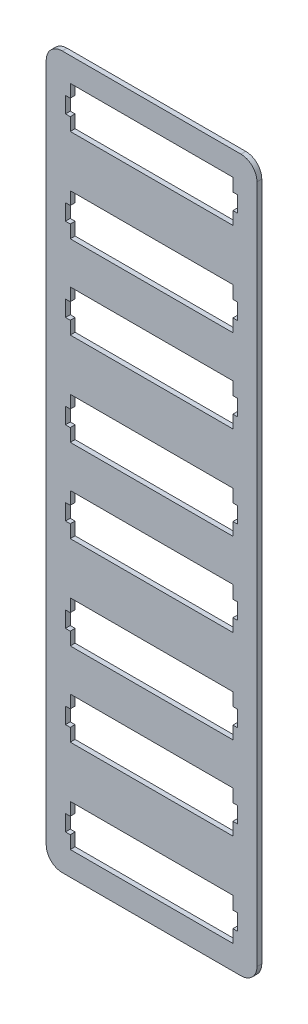
from build123d import *

# Parameters (mm, degrees)
SKIZZE1_W                       = 131.5
SKIZZE1_H                       = 114
SKIZZE1_W_2                     = 101.5
SKIZZE1_H_2                     = 26
AUFSATZ_LINEAR_AUSTRAGEN1_DEPTH = 3
SKIZZE2_W                       = 3
SKIZZE2_H                       = 10
SCHNITT_LINEAR_AUSTRAGEN2_DEPTH = 3
LINEARES_MUSTER2_COUNT          = 4
LINEARES_MUSTER2_PITCH          = 110
VERRUNDUNG1_R                   = 10


with BuildPart() as part:
    # Skizze1 → Aufsatz-Linear austragen1 (new body)
    with BuildSketch(Plane.XY):
        with Locations((65.75, 57)):
            Rectangle(SKIZZE1_W, SKIZZE1_H)
        with Locations((65.75, 28)):
            Rectangle(SKIZZE1_W_2, SKIZZE1_H_2, mode=Mode.SUBTRACT)
        with Locations((65.75, 86)):
            Rectangle(SKIZZE1_W_2, SKIZZE1_H_2, mode=Mode.SUBTRACT)
    aufsatz_linear_austragen1 = extrude(amount=AUFSATZ_LINEAR_AUSTRAGEN1_DEPTH)

    # Skizze2 → Schnitt-Linear austragen2 (cut)
    with BuildSketch(Plane.XY.offset(3)):
        with Locations((13.5, 86)):
            Rectangle(SKIZZE2_W, SKIZZE2_H)
        with Locations((118, 86)):
            Rectangle(SKIZZE2_W, SKIZZE2_H)
        with Locations((13.5, 28)):
            Rectangle(SKIZZE2_W, SKIZZE2_H)
        with Locations((118, 28)):
            Rectangle(SKIZZE2_W, SKIZZE2_H)
    schnitt_linear_austragen2 = extrude(amount=-SCHNITT_LINEAR_AUSTRAGEN2_DEPTH, mode=Mode.SUBTRACT)

    # Lineares Muster2: Aufsatz-Linear austragen1, Schnitt-Linear austragen2 ×4
    with Locations(*[(0, -i * LINEARES_MUSTER2_PITCH, 0) for i in range(1, LINEARES_MUSTER2_COUNT)]):
        add(aufsatz_linear_austragen1)
        add(schnitt_linear_austragen2, mode=Mode.SUBTRACT)

    # Verrundung1
    verrundung1_edges = [part.edges().sort_by_distance(p)[0] for p in [
        (131.5, -330, 1.5),
        (0, -330, 1.5),
        (0, 114, 1.5),
        (131.5, 114, 1.5),
    ]]
    fillet(verrundung1_edges, radius=VERRUNDUNG1_R)


solid = part.part
